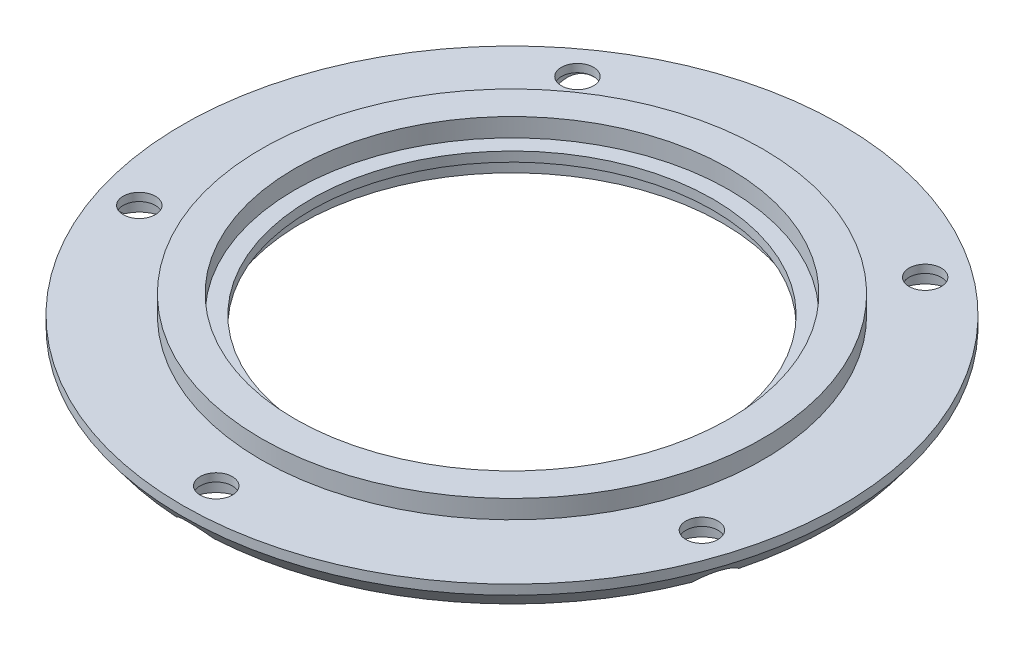
from build123d import *

# Parameters (mm, degrees)
ESQUISSE2_R             = 1
ENL_V_MAT_EXTRU_1_DEPTH = 2.6
ESQUISSE3_R             = 1.75
ENL_V_MAT_EXTRU_2_DEPTH = 1.1


with BuildPart() as part:
    # Esquisse1 → Révolution1 (revolve)
    with BuildSketch(Plane(origin=(0, 0, 0), x_dir=(0, 0, -1), z_dir=(1, 0, 0)), mode=Mode.PRIVATE) as r_volution1_sk:
        Polygon((-13.5, 0), (-13.5, 1.15), (-15.6, 1.15), (-15.6, 0), (-20.5, 0), (-20.5, -0.6), (-19.75, -1.6), (-13.1, -1.6), (-13.1, -0.6), (-12.5, -0.6), (-12.5, 0), align=None)
    revolve(r_volution1_sk.sketch.rotate(Axis((0, -40.878639624, 0), (0, 1, 0)), 180), axis=Axis((0, -40.878639624, 0), (0, 1, 0)))  # turned: the seam where the file's is

    # Esquisse2 → Enlèv. mat.-Extru.1 (cut, through all)
    with BuildSketch(Plane(origin=(0, 0, 0), x_dir=(1, 0, 0), z_dir=(0, 1, 0))):
        with Locations(Location((0, -18.4, 0), (0, 0, 270))):  # turned: the seam where the file's is
            Circle(ESQUISSE2_R)
        with Locations(Location((17.4994399, -5.685912696, 0), (0, 0, 270))):  # turned: the seam where the file's is
            Circle(ESQUISSE2_R)
        with Locations(Location((10.815248642, 14.885912696, 0), (0, 0, 270))):  # turned: the seam where the file's is
            Circle(ESQUISSE2_R)
        with Locations(Location((-10.815248642, 14.885912696, 0), (0, 0, 270))):  # turned: the seam where the file's is
            Circle(ESQUISSE2_R)
        with Locations(Location((-17.4994399, -5.685912696, 0), (0, 0, 270))):  # turned: the seam where the file's is
            Circle(ESQUISSE2_R)
    extrude(amount=-ENL_V_MAT_EXTRU_1_DEPTH, mode=Mode.SUBTRACT)

    # Esquisse3 → Enlèv. mat.-Extru.2 (cut)
    with BuildSketch(Plane.XZ.offset(1.6)):
        with Locations(Location((0, 18.4, 0), (0, 0, 270))):  # turned: the seam where the file's is
            Circle(ESQUISSE3_R)
        with Locations(Location((17.4994399, 5.685912696, 0), (0, 0, 270))):  # turned: the seam where the file's is
            Circle(ESQUISSE3_R)
        with Locations(Location((10.815248642, -14.885912696, 0), (0, 0, 270))):  # turned: the seam where the file's is
            Circle(ESQUISSE3_R)
        with Locations(Location((-10.815248642, -14.885912696, 0), (0, 0, 270))):  # turned: the seam where the file's is
            Circle(ESQUISSE3_R)
        with Locations(Location((-17.4994399, 5.685912696, 0), (0, 0, 270))):  # turned: the seam where the file's is
            Circle(ESQUISSE3_R)
    extrude(amount=-ENL_V_MAT_EXTRU_2_DEPTH, mode=Mode.SUBTRACT)


solid = part.part
